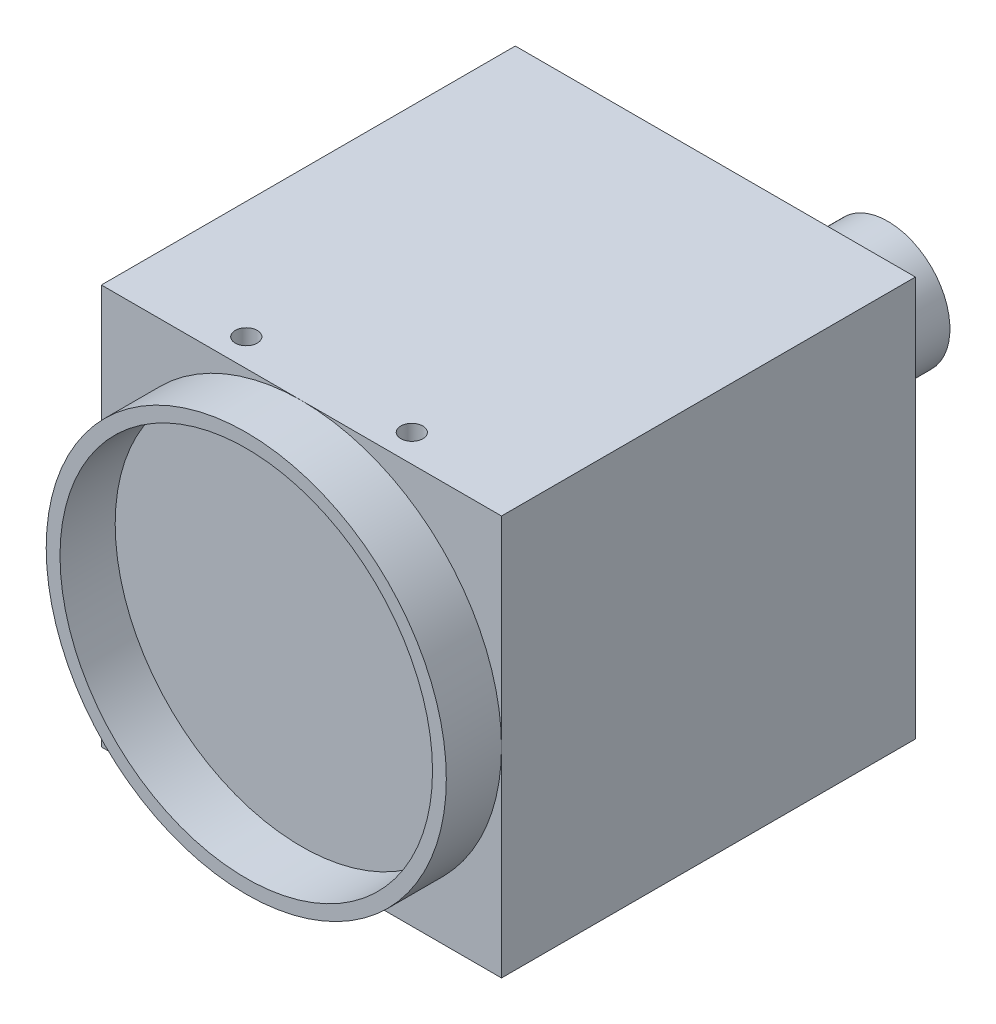
from build123d import *

# Parameters (mm, degrees)
SKETCH1_W                 = 29
SKETCH1_H                 = 29
BOSS_EXTRUDE1_DEPTH       = 30
M2X0_4_TAPPED_HOLE1_D     = 1.6
M2X0_4_TAPPED_HOLE1_DEPTH = 2.5
M2X0_4_TAPPED_HOLE1_TIP   = 0.480688495
M3X0_5_TAPPED_HOLE1_D     = 2.5
M3X0_5_TAPPED_HOLE1_DEPTH = 2.8
M3X0_5_TAPPED_HOLE1_TIP   = 0.751075774
M3X0_5_TAPPED_HOLE2_D     = 2.5
M3X0_5_TAPPED_HOLE2_DEPTH = 2.5
M3X0_5_TAPPED_HOLE2_TIP   = 0.751075774
M2X0_4_TAPPED_HOLE2_D     = 1.6
M2X0_4_TAPPED_HOLE2_DEPTH = 2.5
M2X0_4_TAPPED_HOLE2_TIP   = 0.480688495
M2X0_4_TAPPED_HOLE3_D     = 1.6
M2X0_4_TAPPED_HOLE3_DEPTH = 2
M2X0_4_TAPPED_HOLE3_TIP   = 0.480688495
SKETCH12_R                = 1.000276531
SKETCH12_R_2              = 1
SKETCH12_W                = 10
SKETCH12_H                = 2
CUT_EXTRUDE4_DEPTH        = 3
SKETCH13_R                = 4.5
BOSS_EXTRUDE2_DEPTH       = 4
SKETCH14_R                = 14.5
SKETCH14_R_2              = 13.5
BOSS_EXTRUDE3_DEPTH       = 4


with BuildPart() as part:
    # Sketch1 → Boss-Extrude1 (new body)
    with BuildSketch(Plane.XY):
        Rectangle(SKETCH1_W, SKETCH1_H)
    extrude(amount=BOSS_EXTRUDE1_DEPTH)

    # M2x0.4 Tapped Hole1
    with Locations(Plane(origin=(0, 14.5, 0), x_dir=(1, 0, 0), z_dir=(0, 1, 0))):
        with Locations((-6, -28), (6, -28)):
            Hole(M2X0_4_TAPPED_HOLE1_D / 2, depth=M2X0_4_TAPPED_HOLE1_DEPTH)
            with Locations((0, 0, -(M2X0_4_TAPPED_HOLE1_DEPTH + M2X0_4_TAPPED_HOLE1_TIP / 2))):  # 118° drill point
                Cone(0, M2X0_4_TAPPED_HOLE1_D / 2, M2X0_4_TAPPED_HOLE1_TIP, mode=Mode.SUBTRACT)

    # M3x0.5 Tapped Hole1
    with Locations(Plane(origin=(0, -14.5, 0), x_dir=(-1, 0, 0), z_dir=(0, -1, 0))):
        with Locations((-10, -27), (10, -27)):
            Hole(M3X0_5_TAPPED_HOLE1_D / 2, depth=M3X0_5_TAPPED_HOLE1_DEPTH)
            with Locations((0, 0, -(M3X0_5_TAPPED_HOLE1_DEPTH + M3X0_5_TAPPED_HOLE1_TIP / 2))):  # 118° drill point
                Cone(0, M3X0_5_TAPPED_HOLE1_D / 2, M3X0_5_TAPPED_HOLE1_TIP, mode=Mode.SUBTRACT)

    # M3x0.5 Tapped Hole2
    with Locations(Plane(origin=(0, -14.5, 0), x_dir=(-1, 0, 0), z_dir=(0, -1, 0))):
        with Locations((0, -3.3)):
            Hole(M3X0_5_TAPPED_HOLE2_D / 2, depth=M3X0_5_TAPPED_HOLE2_DEPTH)
            with Locations((0, 0, -(M3X0_5_TAPPED_HOLE2_DEPTH + M3X0_5_TAPPED_HOLE2_TIP / 2))):  # 118° drill point
                Cone(0, M3X0_5_TAPPED_HOLE2_D / 2, M3X0_5_TAPPED_HOLE2_TIP, mode=Mode.SUBTRACT)

    # M2x0.4 Tapped Hole2
    with Locations(Plane(origin=(0, -14.5, 0), x_dir=(-1, 0, 0), z_dir=(0, -1, 0))):
        with Locations((-6, -25.5), (6, -25.5)):
            Hole(M2X0_4_TAPPED_HOLE2_D / 2, depth=M2X0_4_TAPPED_HOLE2_DEPTH)
            with Locations((0, 0, -(M2X0_4_TAPPED_HOLE2_DEPTH + M2X0_4_TAPPED_HOLE2_TIP / 2))):  # 118° drill point
                Cone(0, M2X0_4_TAPPED_HOLE2_D / 2, M2X0_4_TAPPED_HOLE2_TIP, mode=Mode.SUBTRACT)

    # M2x0.4 Tapped Hole3
    with Locations(Plane(origin=(0, -14.5, 0), x_dir=(-1, 0, 0), z_dir=(0, -1, 0))):
        with Locations((-6, -3.3), (6, -3.3)):
            Hole(M2X0_4_TAPPED_HOLE3_D / 2, depth=M2X0_4_TAPPED_HOLE3_DEPTH)
            with Locations((0, 0, -(M2X0_4_TAPPED_HOLE3_DEPTH + M2X0_4_TAPPED_HOLE3_TIP / 2))):  # 118° drill point
                Cone(0, M2X0_4_TAPPED_HOLE3_D / 2, M2X0_4_TAPPED_HOLE3_TIP, mode=Mode.SUBTRACT)

    # Sketch12 → Cut-Extrude4 (cut)
    with BuildSketch(Plane(origin=(0, 0, 0), x_dir=(-1, 0, 0), z_dir=(0, 0, -1))):
        with Locations((6.5, -10.000276531)):
            Circle(SKETCH12_R)
        with Locations((-6.5, -10)):
            Circle(SKETCH12_R_2)
        with Locations((0, -10)):
            Rectangle(SKETCH12_W, SKETCH12_H)
    extrude(amount=-CUT_EXTRUDE4_DEPTH, mode=Mode.SUBTRACT)

    # Sketch13 → Boss-Extrude2 (add)
    with BuildSketch(Plane(origin=(0, 0, 0), x_dir=(-1, 0, 0), z_dir=(0, 0, -1))):
        with Locations((-8.5, 8.5)):
            Circle(SKETCH13_R)
    extrude(amount=BOSS_EXTRUDE2_DEPTH)

    # Sketch14 → Boss-Extrude3 (add)
    with BuildSketch(Plane.XY.offset(30)):
        Circle(SKETCH14_R)
        Circle(SKETCH14_R_2, mode=Mode.SUBTRACT)
    extrude(amount=BOSS_EXTRUDE3_DEPTH)


solid = part.part
